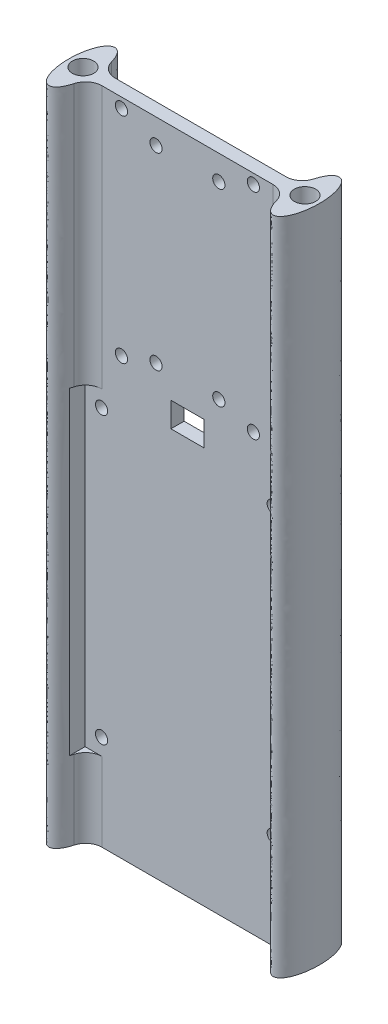
from build123d import *

# Parameters (mm, degrees)
SKETCH1_R               = 3.2385
BOSS_EXTRUDE1_DEPTH     = 200
FILLET1_R               = 5
CUT_EXTRUDE1_DEPTH      = 9.0000001
CUT_EXTRUDE1_DEPTH_BACK = 13.0000001
SKETCH2_W               = 10
SKETCH2_H               = 7.5
CUT_EXTRUDE2_DEPTH      = 9.0000001
CUT_EXTRUDE2_DEPTH_BACK = 13.0000001
SKETCH4_W               = 62.06
SKETCH4_H               = 96.5
CUT_EXTRUDE3_DEPTH      = 10


with BuildPart() as part:
    # Sketch1 → Boss-Extrude1 (new body)
    with BuildSketch(Plane(origin=(0, 0, 0), x_dir=(1, 0, 0), z_dir=(0, 1, 0))):
        with BuildLine():
            add(Edge.make_bspline(
                [(30.080816412, -2), (30.734013676, -10), (34, -10)],
                knots=[4.913746901, 4.913746901, 4.913746901, 6.283185307, 6.283185307, 6.283185307], degree=2, weights=[1, 0.774596669, 1]))
            add(Edge.make_bspline(
                [(34, -10), (42.429964119, -10), (37.098386677, 6.32455532), (31.766809235, 22.649110641), (30.080816412, 2)],
                knots=[0, 0, 0, 2.25551553, 2.25551553, 4.51103106, 4.51103106, 4.51103106], degree=2, weights=[1, 0.428686638, 1, 0.428686638, 1]))
            Line((30.080816412, 2), (-30.080816412, 2))
            add(Edge.make_bspline(
                [(-30.080816412, 2), (-31.766809235, 22.649110641), (-37.098386677, 6.32455532), (-42.429964119, -10), (-34, -10)],
                knots=[1.772154248, 1.772154248, 1.772154248, 4.027669777, 4.027669777, 6.283185307, 6.283185307, 6.283185307], degree=2, weights=[1, 0.428686638, 1, 0.428686638, 1]))
            add(Edge.make_bspline(
                [(-34, -10), (-30.734013676, -10), (-30.080816412, -2)],
                knots=[0, 0, 0, 1.369438406, 1.369438406, 1.369438406], degree=2, weights=[1, 0.774596669, 1]))
            Line((-30.080816412, -2), (30.080816412, -2))
        make_face()
        with Locations((33.655, 0)):
            Circle(SKETCH1_R, mode=Mode.SUBTRACT)
        with Locations((-33.655, 0)):
            Circle(SKETCH1_R, mode=Mode.SUBTRACT)
    extrude(amount=BOSS_EXTRUDE1_DEPTH)

    # Fillet1
    fillet1_edges = [part.edges().sort_by_distance(p)[0] for p in [
        (30.080816412, 100, -2),
        (30.080816412, 100, 2),
        (-30.080816412, 100, -2),
        (-30.080816412, 100, 2),
    ]]
    fillet(fillet1_edges, radius=FILLET1_R)

    # Sketch3 → Cut-Extrude1 (cut, two sides)
    with BuildSketch(Plane(origin=(0, 0, -2), x_dir=(-1, 0, 0), z_dir=(0, 0, -1))) as cut_extrude1_sk:
        with BuildLine():
            ThreePointArc((-18.15, 197), (-21.308147545, 198.308147545), (-20, 195.15))
            Line((-20, 195.15), (-20, 197))
            Line((-20, 197), (-18.15, 197))
        make_face()
        with BuildLine():
            Line((-20, 197), (-20, 195.15))
            ThreePointArc((-20, 195.15), (-18.691852455, 195.691852455), (-18.15, 197))
            Line((-18.15, 197), (-20, 197))
        make_face()
        with BuildLine():
            ThreePointArc((18.15, 197), (18.691852455, 195.691852455), (20, 195.15))
            Line((20, 195.15), (20, 197))
            Line((20, 197), (18.15, 197))
        make_face()
        with BuildLine():
            Line((20, 197), (20, 195.15))
            ThreePointArc((20, 195.15), (21.308147545, 195.691852455), (21.85, 197))
            ThreePointArc((21.85, 197), (20, 198.85), (18.15, 197))
            Line((18.15, 197), (20, 197))
        make_face()
        with BuildLine():
            ThreePointArc((-20, 133.85), (-21.308147545, 130.691852455), (-18.15, 132))
            Line((-18.15, 132), (-20, 132))
            Line((-20, 132), (-20, 133.85))
        make_face()
        with BuildLine():
            Line((-20, 132), (-18.15, 132))
            ThreePointArc((-18.15, 132), (-18.691852455, 133.308147545), (-20, 133.85))
            Line((-20, 133.85), (-20, 132))
        make_face()
        with BuildLine():
            ThreePointArc((20, 133.85), (18.691852455, 133.308147545), (18.15, 132))
            Line((18.15, 132), (20, 132))
            Line((20, 132), (20, 133.85))
        make_face()
        with BuildLine():
            Line((20, 132), (18.15, 132))
            ThreePointArc((18.15, 132), (20, 130.15), (21.85, 132))
            ThreePointArc((21.85, 132), (21.308147545, 133.308147545), (20, 133.85))
            Line((20, 133.85), (20, 132))
        make_face()
    extrude(amount=CUT_EXTRUDE1_DEPTH, mode=Mode.SUBTRACT)
    extrude(cut_extrude1_sk.sketch, amount=-CUT_EXTRUDE1_DEPTH_BACK, mode=Mode.SUBTRACT)

    # Sketch2 → Cut-Extrude2 (cut, two sides)
    with BuildSketch(Plane.XY.offset(2)) as cut_extrude2_sk:
        with BuildLine():
            Line((-25.885263071, 27.005670523), (-25.885263071, 28.85))
            Line((-25.885263071, 28.85), (-26.03, 28.85))
            Line((-26.03, 28.85), (-26.03, 30.7))
            ThreePointArc((-26.03, 30.7), (-27.878581826, 28.777576017), (-25.885263071, 27.005670523))
        make_face()
        with BuildLine():
            Line((-26.03, 28.85), (-25.885263071, 28.85))
            Line((-25.885263071, 28.85), (-25.885263071, 30.694329477))
            ThreePointArc((-25.885263071, 30.694329477), (-25.957576017, 30.698581826), (-26.03, 30.7))
            Line((-26.03, 30.7), (-26.03, 28.85))
        make_face()
        with BuildLine():
            ThreePointArc((-25.885263071, 27.005670523), (-24.671643766, 27.594066745), (-24.18, 28.85))
            Line((-24.18, 28.85), (-25.885263071, 28.85))
            Line((-25.885263071, 28.85), (-25.885263071, 27.005670523))
        make_face()
        with BuildLine():
            Line((-25.885263071, 28.85), (-24.18, 28.85))
            ThreePointArc((-24.18, 28.85), (-24.671643766, 30.105933255), (-25.885263071, 30.694329477))
            Line((-25.885263071, 30.694329477), (-25.885263071, 28.85))
        make_face()
        with BuildLine():
            Line((26.03, 30.7), (26.03, 28.85))
            Line((26.03, 28.85), (25.885263071, 28.85))
            Line((25.885263071, 28.85), (25.885263071, 27.005670523))
            ThreePointArc((25.885263071, 27.005670523), (27.285933255, 27.491643766), (27.88, 28.85))
            ThreePointArc((27.88, 28.85), (27.338147545, 30.158147545), (26.03, 30.7))
        make_face()
        with BuildLine():
            Line((25.885263071, 28.85), (26.03, 28.85))
            Line((26.03, 28.85), (26.03, 30.7))
            ThreePointArc((26.03, 30.7), (25.957576017, 30.698581826), (25.885263071, 30.694329477))
            Line((25.885263071, 30.694329477), (25.885263071, 28.85))
        make_face()
        with BuildLine():
            Line((25.885263071, 27.005670523), (25.885263071, 28.85))
            Line((25.885263071, 28.85), (24.18, 28.85))
            ThreePointArc((24.18, 28.85), (24.671643766, 27.594066745), (25.885263071, 27.005670523))
        make_face()
        with BuildLine():
            Line((24.18, 28.85), (25.885263071, 28.85))
            Line((25.885263071, 28.85), (25.885263071, 30.694329477))
            ThreePointArc((25.885263071, 30.694329477), (24.671643766, 30.105933255), (24.18, 28.85))
        make_face()
        with BuildLine():
            ThreePointArc((25.885263071, 113.505670523), (25.957576017, 113.501418174), (26.03, 113.5))
            Line((26.03, 113.5), (26.03, 115.35))
            Line((26.03, 115.35), (25.885263071, 115.35))
            Line((25.885263071, 115.35), (25.885263071, 113.505670523))
        make_face()
        with BuildLine():
            Line((26.03, 115.35), (26.03, 113.5))
            ThreePointArc((26.03, 113.5), (27.338147545, 114.041852455), (27.88, 115.35))
            ThreePointArc((27.88, 115.35), (27.285933255, 116.708356234), (25.885263071, 117.194329477))
            Line((25.885263071, 117.194329477), (25.885263071, 115.35))
            Line((25.885263071, 115.35), (26.03, 115.35))
        make_face()
        with BuildLine():
            ThreePointArc((24.18, 115.35), (24.671643766, 114.094066745), (25.885263071, 113.505670523))
            Line((25.885263071, 113.505670523), (25.885263071, 115.35))
            Line((25.885263071, 115.35), (24.18, 115.35))
        make_face()
        with BuildLine():
            ThreePointArc((25.885263071, 117.194329477), (24.671643766, 116.605933255), (24.18, 115.35))
            Line((24.18, 115.35), (25.885263071, 115.35))
            Line((25.885263071, 115.35), (25.885263071, 117.194329477))
        make_face()
        with BuildLine():
            ThreePointArc((-26.03, 113.5), (-25.957576017, 113.501418174), (-25.885263071, 113.505670523))
            Line((-25.885263071, 113.505670523), (-25.885263071, 115.35))
            Line((-25.885263071, 115.35), (-26.03, 115.35))
            Line((-26.03, 115.35), (-26.03, 113.5))
        make_face()
        with BuildLine():
            ThreePointArc((-25.885263071, 117.194329477), (-27.878581826, 115.422423983), (-26.03, 113.5))
            Line((-26.03, 113.5), (-26.03, 115.35))
            Line((-26.03, 115.35), (-25.885263071, 115.35))
            Line((-25.885263071, 115.35), (-25.885263071, 117.194329477))
        make_face()
        with BuildLine():
            Line((-25.885263071, 115.35), (-25.885263071, 113.505670523))
            ThreePointArc((-25.885263071, 113.505670523), (-24.671643766, 114.094066745), (-24.18, 115.35))
            Line((-24.18, 115.35), (-25.885263071, 115.35))
        make_face()
        with BuildLine():
            Line((-25.885263071, 115.35), (-24.18, 115.35))
            ThreePointArc((-24.18, 115.35), (-24.671643766, 116.605933255), (-25.885263071, 117.194329477))
            Line((-25.885263071, 117.194329477), (-25.885263071, 115.35))
        make_face()
        with Locations((0, 124.1)):
            Rectangle(SKETCH2_W, SKETCH2_H)
        with BuildLine():
            ThreePointArc((11.375, 135.35), (10.833147545, 136.658147545), (9.525, 137.2))
            Line((9.525, 137.2), (9.525, 135.35))
            Line((9.525, 135.35), (7.675, 135.35))
            ThreePointArc((7.675, 135.35), (9.525, 133.5), (11.375, 135.35))
        make_face()
        with BuildLine():
            Line((9.525, 135.35), (9.525, 137.2))
            ThreePointArc((9.525, 137.2), (8.216852455, 136.658147545), (7.675, 135.35))
            Line((7.675, 135.35), (9.525, 135.35))
        make_face()
        with BuildLine():
            ThreePointArc((-7.675, 135.35), (-8.216852455, 136.658147545), (-9.525, 137.2))
            Line((-9.525, 137.2), (-9.525, 135.35))
            Line((-9.525, 135.35), (-7.675, 135.35))
        make_face()
        with BuildLine():
            Line((-9.525, 135.35), (-9.525, 137.2))
            ThreePointArc((-9.525, 137.2), (-10.833147545, 134.041852455), (-7.675, 135.35))
            Line((-7.675, 135.35), (-9.525, 135.35))
        make_face()
        with BuildLine():
            Line((-9.525, 190.65), (-9.525, 192.5))
            Line((-9.525, 192.5), (-7.675, 192.5))
            ThreePointArc((-7.675, 192.5), (-10.833147545, 193.808147545), (-9.525, 190.65))
        make_face()
        with BuildLine():
            Line((-7.675, 192.5), (-9.525, 192.5))
            Line((-9.525, 192.5), (-9.525, 190.65))
            ThreePointArc((-9.525, 190.65), (-8.216852455, 191.191852455), (-7.675, 192.5))
        make_face()
        with BuildLine():
            ThreePointArc((11.375, 192.5), (9.525, 194.35), (7.675, 192.5))
            Line((7.675, 192.5), (9.525, 192.5))
            Line((9.525, 192.5), (9.525, 190.65))
            ThreePointArc((9.525, 190.65), (10.833147545, 191.191852455), (11.375, 192.5))
        make_face()
        with BuildLine():
            Line((9.525, 192.5), (7.675, 192.5))
            ThreePointArc((7.675, 192.5), (8.216852455, 191.191852455), (9.525, 190.65))
            Line((9.525, 190.65), (9.525, 192.5))
        make_face()
    extrude(amount=CUT_EXTRUDE2_DEPTH, mode=Mode.SUBTRACT)
    extrude(cut_extrude2_sk.sketch, amount=-CUT_EXTRUDE2_DEPTH_BACK, mode=Mode.SUBTRACT)

    # Sketch4 → Cut-Extrude3 (cut)
    with BuildSketch(Plane.XY.offset(2)):
        with Locations((0, 72.1)):
            Rectangle(SKETCH4_W, SKETCH4_H)
    extrude(amount=CUT_EXTRUDE3_DEPTH, mode=Mode.SUBTRACT)


solid = part.part
